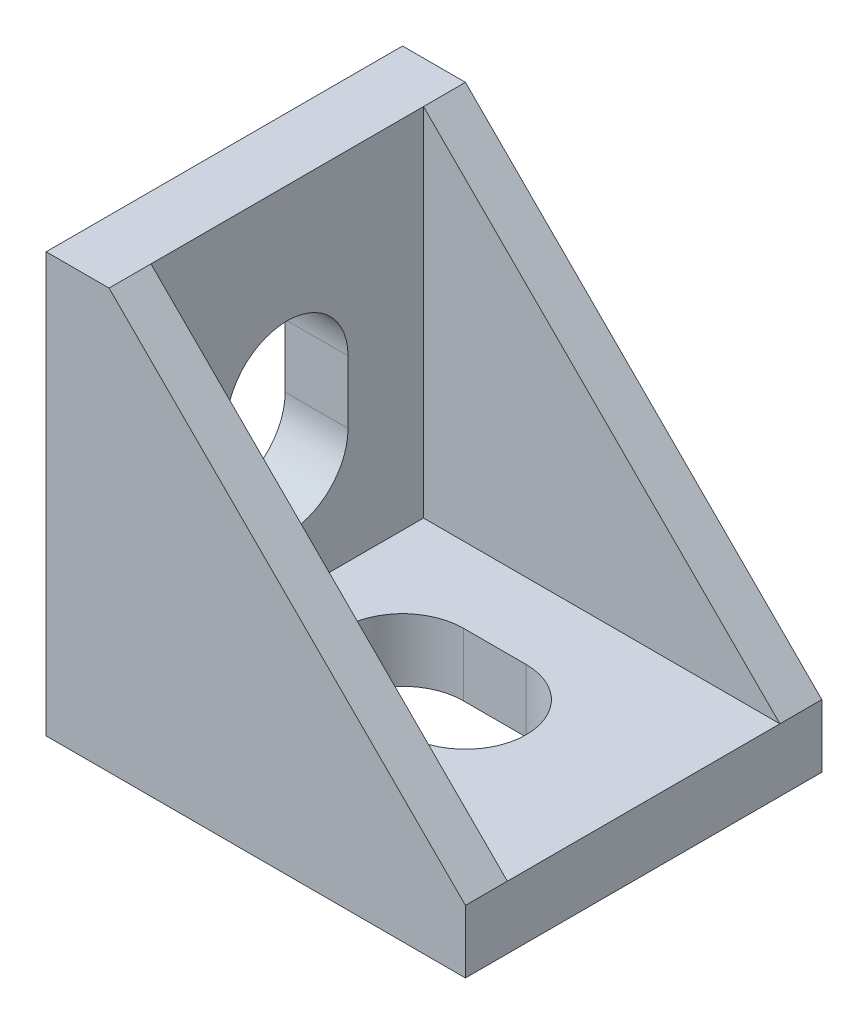
from build123d import *

# Parameters (mm, degrees)
BOSS_EXTRUDE1_DEPTH = 8.5
SKETCH2_W           = 17
SKETCH2_H           = 13
CUT_EXTRUDE1_DEPTH  = 17
CUT_EXTRUDE2_REACH  = 5
CUT_EXTRUDE3_DEPTH  = 4
SKETCH6_W           = 1
SKETCH6_H           = 1.85
SKETCH6_W_2         = 1.85
SKETCH6_H_2         = 1
BOSS_EXTRUDE2_DEPTH = 2


with BuildPart() as part:
    # Sketch1 → Boss-Extrude1 (new body, symmetric)
    with BuildSketch(Plane.XY):
        Polygon((0, 20), (0, 0), (20, 0), (20, 3), (3, 20), align=None)
    extrude(amount=BOSS_EXTRUDE1_DEPTH, both=True)

    # Sketch2 → Cut-Extrude1 (cut)
    with BuildSketch(Plane(origin=(0, 20, 0), x_dir=(1, 0, 0), z_dir=(0, 1, 0))):
        with Locations((11.5, 0)):
            Rectangle(SKETCH2_W, SKETCH2_H)
    extrude(amount=-CUT_EXTRUDE1_DEPTH, mode=Mode.SUBTRACT)

    # Sketch3 → Cut-Extrude2 (cut, up to next)
    with BuildSketch(Plane(origin=(3, 0, 0), x_dir=(0, 0, -1), z_dir=(1, 0, 0)), mode=Mode.PRIVATE) as cut_extrude2_sk1:
        with BuildLine():
            Line((-2.9, 8.5), (-2.9, 11.5))
            ThreePointArc((-2.9, 11.5), (0, 14.4), (2.9, 11.5))
            Line((2.9, 11.5), (2.9, 8.5))
            ThreePointArc((2.9, 8.5), (0, 5.6), (-2.9, 8.5))
        make_face()
    cut_extrude2_tool1 = extrude(cut_extrude2_sk1.sketch, amount=-CUT_EXTRUDE2_REACH, mode=Mode.PRIVATE) & part.part
    add(cut_extrude2_tool1.solids().sort_by_distance((3, 10, 0))[0], mode=Mode.SUBTRACT)

    # Sketch5 → Cut-Extrude3 (cut, through all)
    with BuildSketch(Plane(origin=(0, 3, 0), x_dir=(1, 0, 0), z_dir=(0, 1, 0))):
        with BuildLine():
            Line((11.5, -2.9), (8.5, -2.9))
            ThreePointArc((8.5, -2.9), (5.6, 0), (8.5, 2.9))
            Line((8.5, 2.9), (11.5, 2.9))
            ThreePointArc((11.5, 2.9), (14.4, 0), (11.5, -2.9))
        make_face()
    extrude(amount=-CUT_EXTRUDE3_DEPTH, mode=Mode.SUBTRACT)

    # Sketch6 → Boss-Extrude2 (add, symmetric)
    with BuildSketch(Plane.XY):
        with Locations((-0.5, 17.575)):
            Rectangle(SKETCH6_W, SKETCH6_H)
        with Locations((-0.5, 2.425)):
            Rectangle(SKETCH6_W, SKETCH6_H)
        with Locations((2.425, -0.5)):
            Rectangle(SKETCH6_W_2, SKETCH6_H_2)
        with Locations((17.575, -0.5)):
            Rectangle(SKETCH6_W_2, SKETCH6_H_2)
    extrude(amount=BOSS_EXTRUDE2_DEPTH, both=True)


solid = part.part
